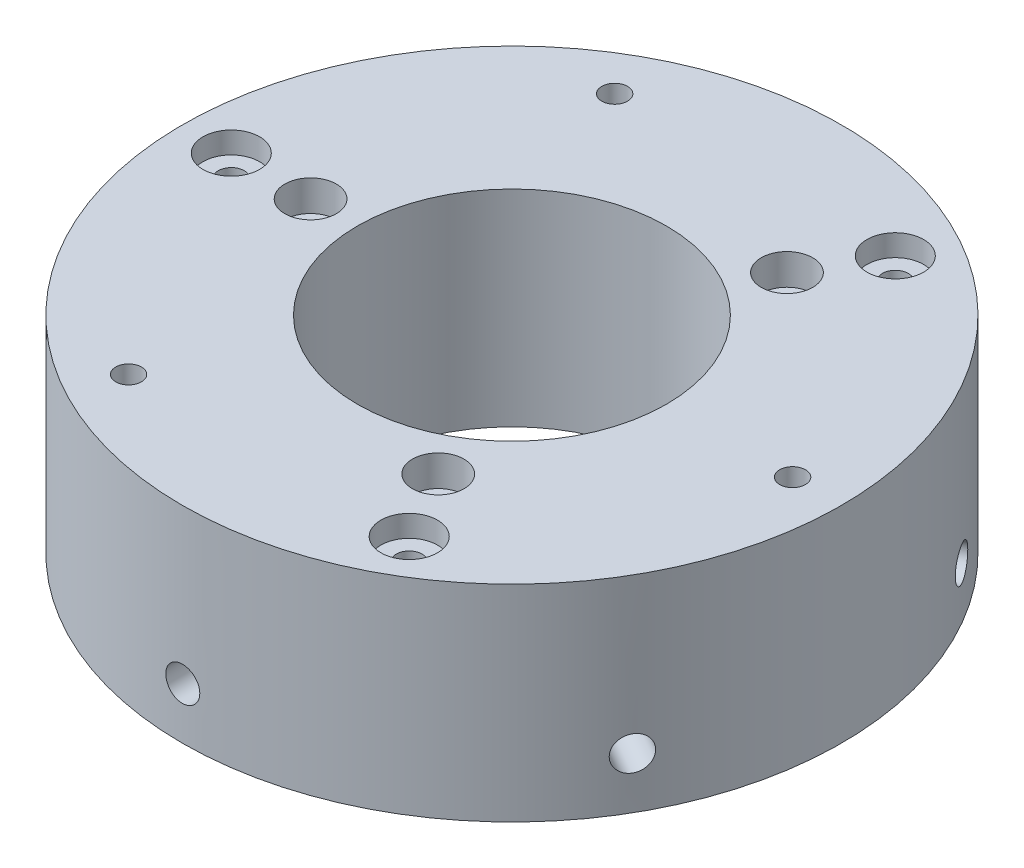
from build123d import *

# Parameters (mm, degrees)
SKETCH_1_R               = 32
SKETCH_1_R_2             = 2.5
SKETCH_1_R_3             = 1.25
EXTRUDE_1_DEPTH          = 20
SKETCH_2_R               = 2.75
CUT_EXTRUDE_1_DEPTH      = 2.1
SKETCH_3_R               = 2.5
CUT_EXTRUDE_2_DEPTH      = 3
SKETCH_4_R               = 1.65
CUT_EXTRUDE_3_DEPTH      = 10
PATTERN_CIRCULAR_1_COUNT = 6
SKETCH_5_R               = 15
CUT_EXTRUDE_4_DEPTH      = 21.0000001
SKETCH_6_R               = 2.75
SKETCH_6_R_2             = 1.25
CUT_EXTRUDE_5_DEPTH      = 3


with BuildPart() as part:
    # 草图1 → 凸台-拉伸1 (new body)
    with BuildSketch(Plane(origin=(0, 0, 0), x_dir=(1, 0, 0), z_dir=(0, 1, 0))):
        Circle(SKETCH_1_R)
        with Locations((-23.599192253, -13.625)):
            Circle(SKETCH_1_R_2, mode=Mode.SUBTRACT)
        with Locations((-13.625, -23.599192253)):
            Circle(SKETCH_1_R_3, mode=Mode.SUBTRACT)
        with Locations((0, -27.25)):
            Circle(SKETCH_1_R_2, mode=Mode.SUBTRACT)
        with Locations((13.625, -23.599192253)):
            Circle(SKETCH_1_R_3, mode=Mode.SUBTRACT)
        with Locations((23.599192253, -13.625)):
            Circle(SKETCH_1_R_2, mode=Mode.SUBTRACT)
        with Locations((27.25, 0)):
            Circle(SKETCH_1_R_3, mode=Mode.SUBTRACT)
        with Locations((23.599192253, 13.625)):
            Circle(SKETCH_1_R_2, mode=Mode.SUBTRACT)
        with Locations((13.625, 23.599192253)):
            Circle(SKETCH_1_R_3, mode=Mode.SUBTRACT)
        with Locations((0, 27.25)):
            Circle(SKETCH_1_R_2, mode=Mode.SUBTRACT)
        with Locations((-13.625, 23.599192253)):
            Circle(SKETCH_1_R_3, mode=Mode.SUBTRACT)
        with Locations((-23.599192253, 13.625)):
            Circle(SKETCH_1_R_2, mode=Mode.SUBTRACT)
        with Locations((-27.25, 0)):
            Circle(SKETCH_1_R_3, mode=Mode.SUBTRACT)
        with Locations((-23.599192253, -13.625)):
            Circle(SKETCH_1_R_2)
        with Locations((-23.599192253, 13.625)):
            Circle(SKETCH_1_R_2)
        with Locations((23.599192253, 13.625)):
            Circle(SKETCH_1_R_2)
        with Locations((0, 27.25)):
            Circle(SKETCH_1_R_2)
        with Locations((0, -27.25)):
            Circle(SKETCH_1_R_2)
        with Locations((23.599192253, -13.625)):
            Circle(SKETCH_1_R_2)
    extrude(amount=EXTRUDE_1_DEPTH)

    # 草图2 → 切除-拉伸1 (cut)
    with BuildSketch(Plane(origin=(0, 20, 0), x_dir=(1, 0, 0), z_dir=(0, 1, 0))):
        with Locations((-27.25, 0)):
            Circle(SKETCH_2_R)
        with Locations((13.625, 23.599192253)):
            Circle(SKETCH_2_R)
        with Locations((13.625, -23.599192253)):
            Circle(SKETCH_2_R)
    extrude(amount=-CUT_EXTRUDE_1_DEPTH, mode=Mode.SUBTRACT)

    # 草图3 → 切除-拉伸2 (cut)
    with BuildSketch(Plane(origin=(0, 20, 0), x_dir=(1, 0, 0), z_dir=(0, 1, 0))):
        with Locations((-19.55, 0)):
            Circle(SKETCH_3_R)
        with Locations((9.775, 16.930796644)):
            Circle(SKETCH_3_R)
        with Locations((9.775, -16.930796644)):
            Circle(SKETCH_3_R)
    extrude(amount=-CUT_EXTRUDE_2_DEPTH, mode=Mode.SUBTRACT)

    # 草图4 → 切除-拉伸3 (cut)
    with BuildSketch(Plane.XY.offset(32)):
        with Locations((0, 5)):
            Circle(SKETCH_4_R)
    cut_extrude_3 = extrude(amount=-CUT_EXTRUDE_3_DEPTH, mode=Mode.SUBTRACT)

    # 阵列(圆周)1: 切除-拉伸3 ×6 about axis
    pattern_circular_1_axis = Axis((0, 0, 0), (0, 1, 0))
    for i in range(1, PATTERN_CIRCULAR_1_COUNT):
        add(cut_extrude_3.rotate(pattern_circular_1_axis, i * 360 / PATTERN_CIRCULAR_1_COUNT), mode=Mode.SUBTRACT)

    # 草图5 → 切除-拉伸4 (cut, through all)
    with BuildSketch(Plane(origin=(0, 20, 0), x_dir=(1, 0, 0), z_dir=(0, 1, 0))):
        Circle(SKETCH_5_R)
    extrude(amount=-CUT_EXTRUDE_4_DEPTH, mode=Mode.SUBTRACT)

    # 草图6 → 切除-拉伸5 (cut)
    with BuildSketch(Plane.XZ):
        with Locations((13.625, -23.599192253)):
            Circle(SKETCH_6_R)
        with Locations((13.625, -23.599192253)):
            Circle(SKETCH_6_R_2, mode=Mode.SUBTRACT)
        with Locations((27.25, 0)):
            Circle(SKETCH_6_R)
        with Locations((27.25, 0)):
            Circle(SKETCH_6_R_2, mode=Mode.SUBTRACT)
        with Locations((13.625, 23.599192253)):
            Circle(SKETCH_6_R)
        with Locations((13.625, 23.599192253)):
            Circle(SKETCH_6_R_2, mode=Mode.SUBTRACT)
        with Locations((-13.625, 23.599192253)):
            Circle(SKETCH_6_R)
        with Locations((-13.625, 23.599192253)):
            Circle(SKETCH_6_R_2, mode=Mode.SUBTRACT)
        with Locations((-27.25, 0)):
            Circle(SKETCH_6_R)
        with Locations((-27.25, 0)):
            Circle(SKETCH_6_R_2, mode=Mode.SUBTRACT)
        with Locations((-13.625, -23.599192253)):
            Circle(SKETCH_6_R)
        with Locations((-13.625, -23.599192253)):
            Circle(SKETCH_6_R_2, mode=Mode.SUBTRACT)
    extrude(amount=-CUT_EXTRUDE_5_DEPTH, mode=Mode.SUBTRACT)


solid = part.part
